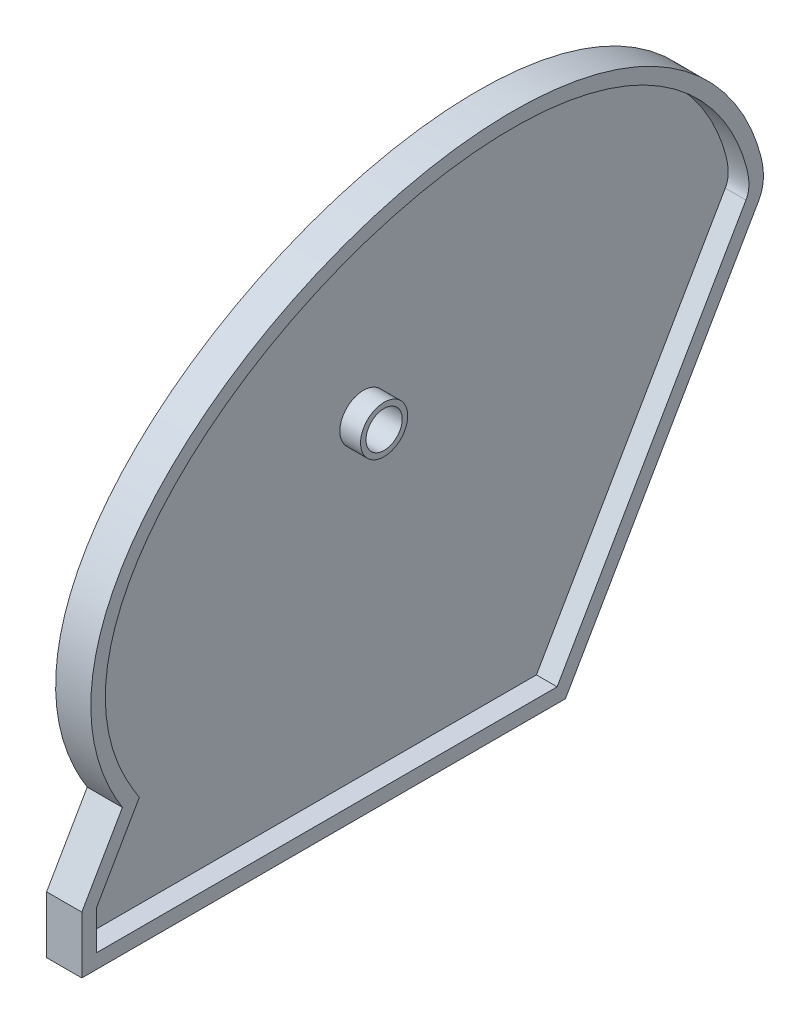
from build123d import *

# Parameters (mm, degrees)
SKETCH1_R                                         = 1.27
BOSS_EXTRUDE1_DEPTH                               = 4.9276
SHELL1_T                                          = -2.032
CSK_FOR_0_FLAT_HEAD_MACHINE_SCREW_100_D           = 5.08
CSK_FOR_0_FLAT_HEAD_MACHINE_SCREW_100_CSINK_D     = 7.62
CSK_FOR_0_FLAT_HEAD_MACHINE_SCREW_100_CSINK_ANGLE = 100


with BuildPart() as part:
    # Sketch1 → Boss-Extrude1 (new body)
    with BuildSketch(Plane(origin=(0, 0, 0), x_dir=(0, 0, -1), z_dir=(1, 0, 0))):
        with BuildLine():
            Line((0, 0), (-67.7418, 0))
            Line((-67.7418, 0), (-67.7418, 7.990379))
            Line((-67.7418, 7.990379), (-62.052733, 17.844133))
            add(Edge.make_bspline(
                [(-62.052733, 17.844133), (-83.520452, 52.181699), (-7.196896, 94.452135), (26.093729, 59.797721), (28.153169, 48.762718), (27.0383, 46.831709)],
                knots=[0, 0, 0, 0, 0.772335, 0.951961, 1, 1, 1, 1], degree=3))
            Line((27.0383, 46.831709), (0, 0))
        make_face()
        with Locations((-25.4, 45.3644)):
            Circle(SKETCH1_R, mode=Mode.SUBTRACT)
    extrude(amount=BOSS_EXTRUDE1_DEPTH)

    # Shell1
    shell1_openings = [part.faces().sort_by_distance(p)[0] for p in [
        (4.9276, 17.432002, 25.190503),
    ]]
    offset(amount=SHELL1_T, openings=shell1_openings, kind=Kind.INTERSECTION)

    # CSK for #0 Flat Head Machine Screw (100)2 (through all)
    with Locations(Plane.ZY):
        with Locations((25.4, 45.3644)):
            CounterSinkHole(CSK_FOR_0_FLAT_HEAD_MACHINE_SCREW_100_D / 2, CSK_FOR_0_FLAT_HEAD_MACHINE_SCREW_100_CSINK_D / 2, counter_sink_angle=CSK_FOR_0_FLAT_HEAD_MACHINE_SCREW_100_CSINK_ANGLE)


solid = part.part
